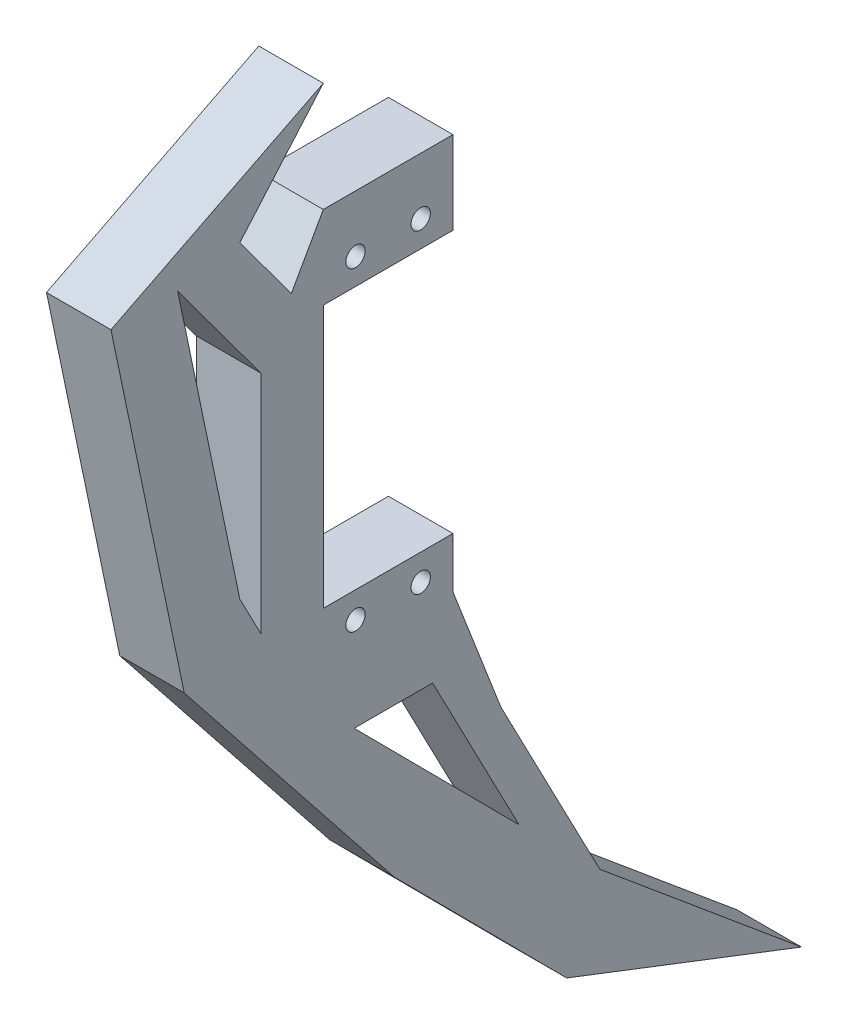
from build123d import *

# Parameters (mm, degrees)
SKETCH_7_R      = 1.5
EXTRUDE_2_DEPTH = 10


with BuildPart() as part:
    # 草图7 → 凸台-拉伸2 (new body)
    with BuildSketch(Plane(origin=(0, 0, 0), x_dir=(0, 0, -1), z_dir=(1, 0, 0))):
        Polygon((74.781222648, -105.314484454), (54.681222648, -105.314484454), (54.681222648, -146.014484454), (74.781222648, -146.014484454), (74.781222648, -153.864484454), (82.217885242, -173.050276706), (97.545045534, -202.471417533), (128.819415354, -228.557286652), (92.419152856, -214.512376165), (65.67699801, -187.583359255), (33.129337627, -146.599083723), (27.518646132, -119.704186977), (21.769974855, -92.147882993), (54.681222648, -75.517443579), (41.74198, -90.455051539), (49.731222648, -101.264484454), (54.681222648, -92.464484454), (65.67699801, -92.464484454), (74.781222648, -92.464484454), align=None)
        with Locations((69.781222648, -150.064484454)):
            Circle(SKETCH_7_R, mode=Mode.SUBTRACT)
        with Locations((59.681222648, -150.064484454)):
            Circle(SKETCH_7_R, mode=Mode.SUBTRACT)
        with Locations((69.781222648, -101.264484454)):
            Circle(SKETCH_7_R, mode=Mode.SUBTRACT)
        with Locations((59.681222648, -101.264484454)):
            Circle(SKETCH_7_R, mode=Mode.SUBTRACT)
        Polygon((85.031406178, -190.25046896), (71.623670801, -164.51374649), (59.47327237, -164.51374649), align=None, mode=Mode.SUBTRACT)
        Polygon((45.003171043, -144.573005818), (41.74198, -138.313009895), (32.111220405, -92.147882993), (45.003171043, -109.590672216), align=None, mode=Mode.SUBTRACT)
    extrude(amount=EXTRUDE_2_DEPTH)


solid = part.part
